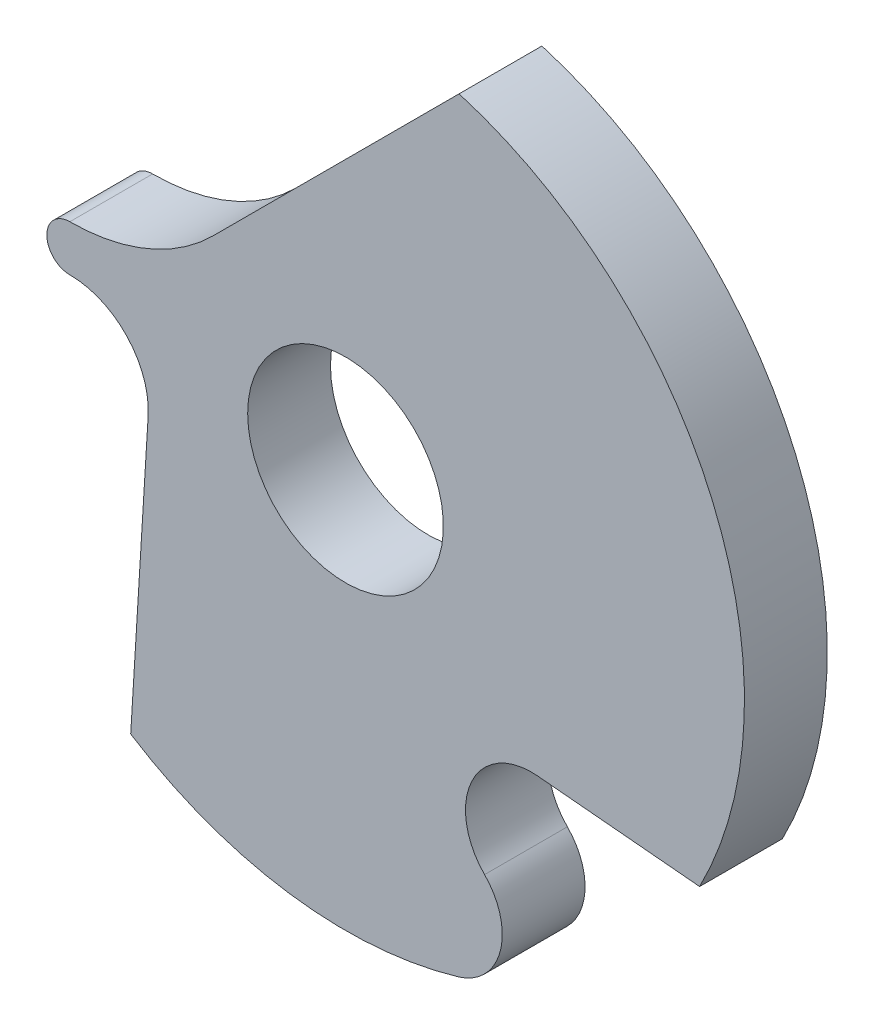
from build123d import *

# Parameters (mm, degrees)
SKETCH1_R           = 0.65
BOSS_EXTRUDE1_DEPTH = 0.55


with BuildPart() as part:
    # Sketch1 → Boss-Extrude1 (new body)
    with BuildSketch(Plane.XY.offset(0.55)):
        with BuildLine():
            Line((1.274233088, -1.122718337), (2.351911214, -1.221070694))
            ThreePointArc((2.351911214, -1.221070694), (2.439127121, 1.035933823), (0.754376305, 2.540357532))
            Line((0.754376305, 2.540357532), (-0.880678776, 0.905302451))
            ThreePointArc((-0.880678776, 0.905302451), (-1.316819724, 0.613882386), (-1.831283051, 0.511549267))
            ThreePointArc((-1.831283051, 0.511549267), (-1.983983424, 0.358848894), (-1.831283051, 0.20614852))
            ThreePointArc((-1.831283051, 0.20614852), (-1.451603036, 0.042010969), (-1.311061008, -0.347021148))
            Line((-1.311061008, -0.347021148), (-1.426950301, -2.233005338))
            ThreePointArc((-1.426950301, -2.233005338), (-0.372010152, -2.623758458), (0.749973232, -2.541660904))
            ThreePointArc((0.749973232, -2.541660904), (1.02832185, -2.253308059), (0.923549505, -1.866464328))
            ThreePointArc((0.923549505, -1.866464328), (0.838647067, -1.371883608), (1.274233088, -1.122718337))
        make_face()
        Circle(SKETCH1_R, mode=Mode.SUBTRACT)
    extrude(amount=-BOSS_EXTRUDE1_DEPTH)


solid = part.part
